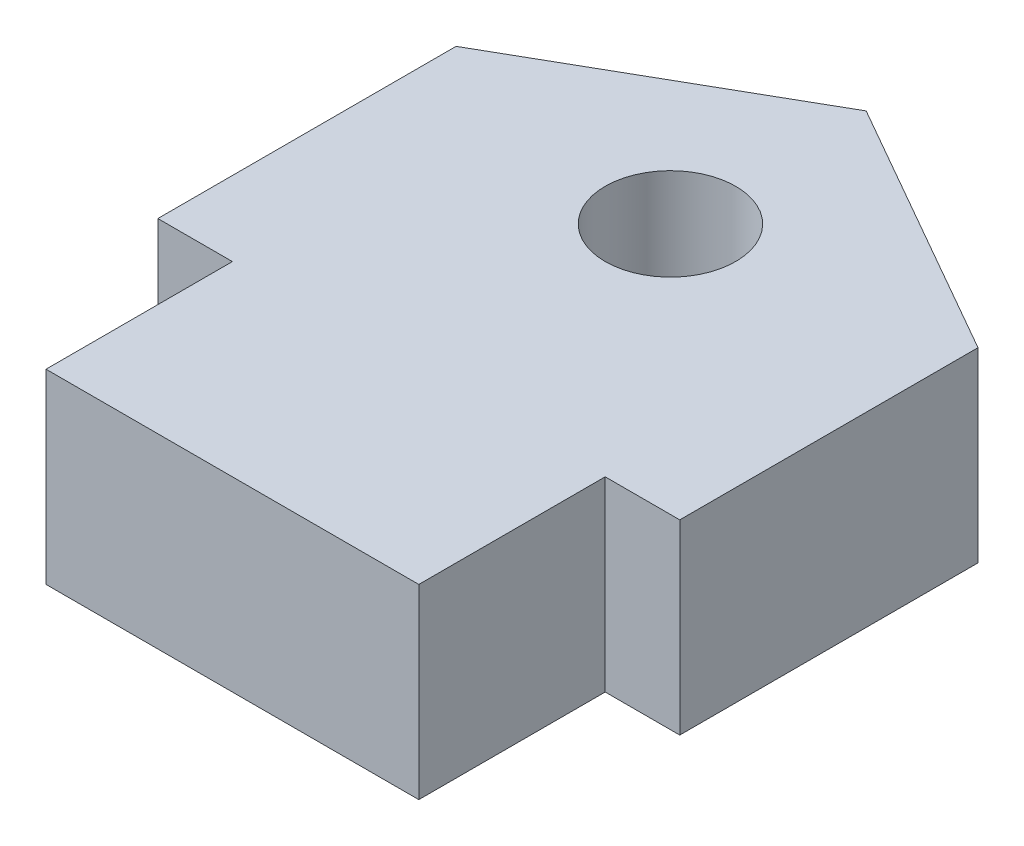
from build123d import *

# Parameters (mm, degrees)
SKETCH2_R           = 1.75
BOSS_EXTRUDE3_DEPTH = 5


with BuildPart() as part:
    # Sketch2 → Boss-Extrude3 (new body)
    with BuildSketch(Plane(origin=(0, 0, 0), x_dir=(1, 0, 0), z_dir=(0, 1, 0))):
        Polygon((-214, -48.75), (-207, -44.75), (-200, -48.75), (-200, -56.75), (-202, -56.75), (-202, -61.75), (-212, -61.75), (-212, -56.75), (-214, -56.75), align=None)
        with Locations((-207, -50)):
            Circle(SKETCH2_R, mode=Mode.SUBTRACT)
    extrude(amount=BOSS_EXTRUDE3_DEPTH)


solid = part.part
